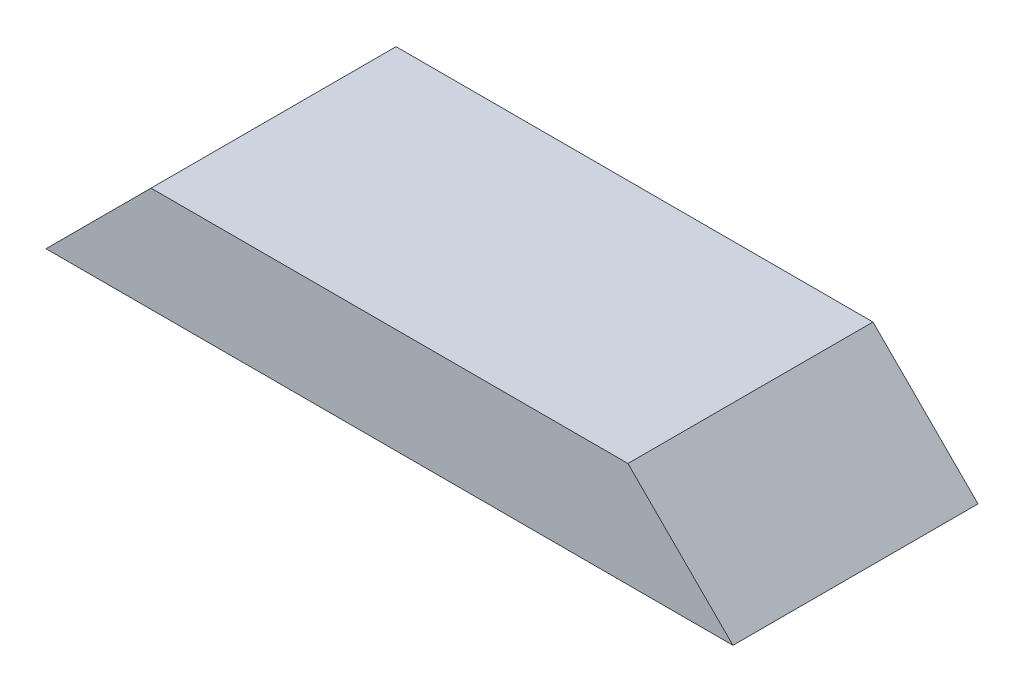
from build123d import *

# Parameters (mm, degrees)
SKETCH1_W           = 249.2375
SKETCH1_H           = 88.9
BOSS_EXTRUDE1_DEPTH = 38.1
CUT_EXTRUDE1_DEPTH  = 89.9


with BuildPart() as part:
    # Sketch1 → Boss-Extrude1 (new body)
    with BuildSketch(Plane(origin=(0, 0, 0), x_dir=(1, 0, 0), z_dir=(0, 1, 0))):
        with Locations((124.61875, 44.45)):
            Rectangle(SKETCH1_W, SKETCH1_H)
    extrude(amount=BOSS_EXTRUDE1_DEPTH)

    # Sketch2 → Cut-Extrude1 (cut, through all)
    with BuildSketch(Plane.XY):
        Polygon((0, 0), (38.1, 38.1), (0, 38.1), align=None)
        Polygon((249.2375, 0), (211.1375, 38.1), (249.2375, 38.1), align=None)
    extrude(amount=-CUT_EXTRUDE1_DEPTH, mode=Mode.SUBTRACT)


solid = part.part
